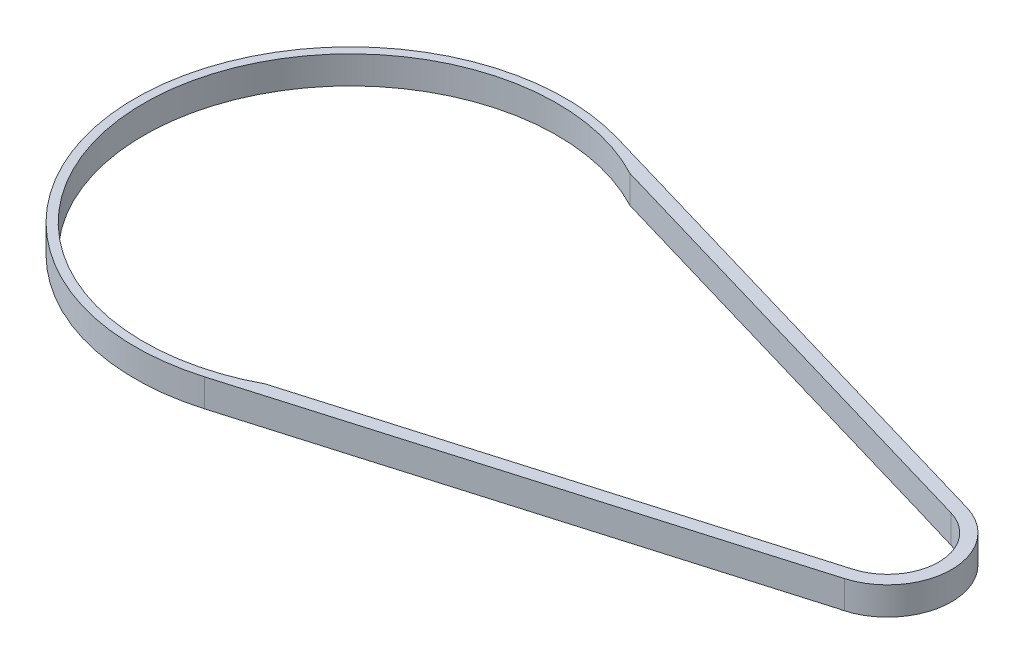
from build123d import *

# Parameters (mm, degrees)
SKETCH1_R               = 50.00602605
SKETCH1_R_2             = 48.00602605
BOSS_EXTRUDE1_DEPTH     = 6.45
EXTRUDE_THIN1_START     = 4.55
SKETCH2_R               = 14.85
SKETCH2_R_2             = 11.85
EXTRUDE_THIN1_DEPTH     = 6.5
BOSS_EXTRUDE2_DEPTH     = 6.45
CUT_EXTRUDE1_DEPTH      = 7.45
CUT_EXTRUDE2_DEPTH      = 7.5
CUT_EXTRUDE3_DEPTH      = 1
CUT_EXTRUDE3_DEPTH_BACK = 7.5


with BuildPart() as part:
    # Sketch1 → Boss-Extrude1 (new body)
    with BuildSketch(Plane(origin=(0, 13.433589084, 0), x_dir=(-1, 0, 0), z_dir=(0, -1, 0))):
        with Locations((-83.776404782, 38.885320672)):
            Circle(SKETCH1_R)
        with Locations((-83.776404782, 38.885320672)):
            Circle(SKETCH1_R_2, mode=Mode.SUBTRACT)
    extrude(amount=BOSS_EXTRUDE1_DEPTH)



with BuildPart() as body_2:
    # Sketch2 → Extrude-Thin1 (new body)
    with BuildSketch(Plane(origin=(0, 17.983589084, 0), x_dir=(-1, 0, 0), z_dir=(0, -1, 0)).offset(EXTRUDE_THIN1_START)):
        with Locations((-208.585951979, 38.885320672)):
            Circle(SKETCH2_R)
        with Locations((-208.585951979, 38.885320672)):
            Circle(SKETCH2_R_2, mode=Mode.SUBTRACT)
    extrude(amount=EXTRUDE_THIN1_DEPTH)


with BuildPart() as part_1:
    add(part.part)

    add(body_2.part)  # Boss-Extrude2 merges body 2
    # Sketch3 → Boss-Extrude2 (add)
    with BuildSketch(Plane(origin=(0, 6.983589084, 0), x_dir=(-1, 0, 0), z_dir=(0, -1, 0))):
        with BuildLine():
            Line((-97.861971102, 86.866561409), (-212.768861048, 53.134031902))
            ThreePointArc((-212.768861048, 53.134031902), (-208.023442769, 53.724663089), (-203.336355819, 52.776477576))
            Line((-203.336355819, 52.776477576), (-113.385956141, 79.182679265))
            ThreePointArc((-113.385956141, 79.182679265), (-105.95919853, 83.701905803), (-97.861971102, 86.866561409))
        make_face()
        with BuildLine():
            Line((-113.385956141, -1.412037922), (-203.336355819, 24.994163767))
            ThreePointArc((-203.336355819, 24.994163767), (-208.023442769, 24.045978254), (-212.768861048, 24.636609441))
            Line((-212.768861048, 24.636609441), (-97.861971102, -9.095920066))
            ThreePointArc((-97.861971102, -9.095920066), (-105.95919853, -5.93126446), (-113.385956141, -1.412037922))
        make_face()
    extrude(amount=-BOSS_EXTRUDE2_DEPTH)

    # Sketch4 → Cut-Extrude1 (cut, through all)
    with BuildSketch(Plane(origin=(0, 6.983589084, 0), x_dir=(-1, 0, 0), z_dir=(0, -1, 0))):
        with BuildLine():
            Line((-113.385956141, 79.182679265), (-106.369670763, 81.242408265))
            ThreePointArc((-106.369670763, 81.242408265), (-131.782430832, 38.885320672), (-106.369670763, -3.471766922))
            Line((-106.369670763, -3.471766922), (-113.385956141, -1.412037922))
            ThreePointArc((-113.385956141, -1.412037922), (-133.782430832, 38.885320672), (-113.385956141, 79.182679265))
        make_face()
    extrude(amount=-CUT_EXTRUDE1_DEPTH, mode=Mode.SUBTRACT)

    # Sketch5 → Cut-Extrude2 (cut, through all)
    with BuildSketch(Plane(origin=(0, 6.933589084, 0), x_dir=(-1, 0, 0), z_dir=(0, -1, 0))):
        with BuildLine():
            Line((-203.336355819, 24.994163767), (-204.770657455, 25.415223133))
            Line((-204.770657455, 25.415223133), (-204.770657455, 52.35541821))
            Line((-204.770657455, 52.35541821), (-203.336355819, 52.776477576))
            ThreePointArc((-203.336355819, 52.776477576), (-193.735951979, 38.885320672), (-203.336355819, 24.994163767))
        make_face()
    extrude(amount=-CUT_EXTRUDE2_DEPTH, mode=Mode.SUBTRACT)

    # Sketch6 → Cut-Extrude3 (cut, two sides)
    with BuildSketch(Plane(origin=(0, 13.433589084, 0), x_dir=(1, 0, 0), z_dir=(0, 1, 0))) as cut_extrude3_sk:
        with BuildLine():
            Line((204.770657455, 25.415223133), (211.923828913, 27.515136963))
            ThreePointArc((211.923828913, 27.515136963), (208.3355607, 27.037966359), (204.770657455, 27.666317699))
            Line((204.770657455, 27.666317699), (204.770657455, 25.415223133))
        make_face()
        with BuildLine():
            Line((204.770657455, 50.104323644), (204.770657455, 52.35541821))
            Line((204.770657455, 52.35541821), (211.923828913, 50.25550438))
            ThreePointArc((211.923828913, 50.25550438), (208.3355607, 50.732674984), (204.770657455, 50.104323644))
        make_face()
    extrude(amount=CUT_EXTRUDE3_DEPTH, mode=Mode.SUBTRACT)
    extrude(cut_extrude3_sk.sketch, amount=-CUT_EXTRUDE3_DEPTH_BACK, mode=Mode.SUBTRACT)


solid = part_1.part
